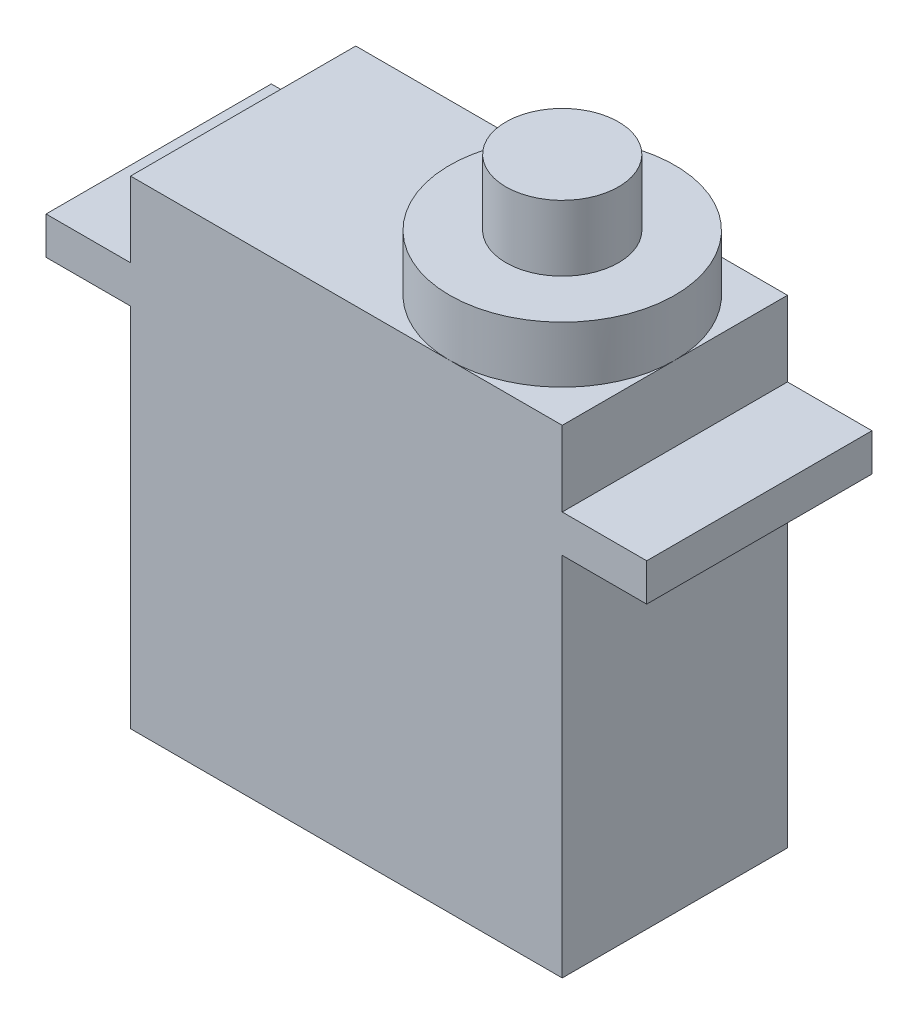
from build123d import *

# Parameters (mm, degrees)
SKETCH1_W           = 23
SKETCH1_H           = 12
BOSS_EXTRUDE1_DEPTH = 19.5
SKETCH2_W           = 4.5
SKETCH2_H           = 12
SKETCH2_W_2         = 23
BOSS_EXTRUDE2_DEPTH = 2
SKETCH3_W           = 23
SKETCH3_H           = 12
BOSS_EXTRUDE3_DEPTH = 4
BOSS_EXTRUDE4_DEPTH = 3
SKETCH5_R           = 3
BOSS_EXTRUDE5_DEPTH = 3.5


with BuildPart() as part:
    # Sketch1 → Boss-Extrude1 (new body)
    with BuildSketch(Plane(origin=(0, 0, 0), x_dir=(1, 0, 0), z_dir=(0, 1, 0))):
        with Locations((11.5, 6)):
            Rectangle(SKETCH1_W, SKETCH1_H)
    extrude(amount=BOSS_EXTRUDE1_DEPTH)

    # Sketch2 → Boss-Extrude2 (add)
    with BuildSketch(Plane(origin=(0, 19.5, 0), x_dir=(1, 0, 0), z_dir=(0, 1, 0))):
        with Locations((-2.25, 6)):
            Rectangle(SKETCH2_W, SKETCH2_H)
        with Locations((25.25, 6)):
            Rectangle(SKETCH2_W, SKETCH2_H)
        with Locations((11.5, 6)):
            Rectangle(SKETCH2_W_2, SKETCH2_H)
    extrude(amount=BOSS_EXTRUDE2_DEPTH)

    # Sketch3 → Boss-Extrude3 (add)
    with BuildSketch(Plane(origin=(0, 21.5, 0), x_dir=(1, 0, 0), z_dir=(0, 1, 0))):
        with Locations((11.5, 6)):
            Rectangle(SKETCH3_W, SKETCH3_H)
    extrude(amount=BOSS_EXTRUDE3_DEPTH)

    # Sketch4 → Boss-Extrude4 (add)
    with BuildSketch(Plane(origin=(0, 25.5, 0), x_dir=(1, 0, 0), z_dir=(0, 1, 0))):
        with BuildLine():
            ThreePointArc((12.757359313, 1.757359313), (14.703899406, 0.456722805), (17, 0))
            ThreePointArc((17, 0), (21.242640687, 1.757359313), (23, 6))
            ThreePointArc((23, 6), (22.543277195, 8.296100594), (21.242640687, 10.242640687))
            Line((21.242640687, 10.242640687), (12.757359313, 1.757359313))
        make_face()
        with BuildLine():
            ThreePointArc((11, 6), (11.456722805, 3.703899406), (12.757359313, 1.757359313))
            Line((12.757359313, 1.757359313), (21.242640687, 10.242640687))
            ThreePointArc((21.242640687, 10.242640687), (19.296100594, 11.543277195), (17, 12))
            ThreePointArc((17, 12), (12.757359313, 10.242640687), (11, 6))
        make_face()
    extrude(amount=BOSS_EXTRUDE4_DEPTH)

    # Sketch5 → Boss-Extrude5 (add)
    with BuildSketch(Plane(origin=(0, 28.5, 0), x_dir=(1, 0, 0), z_dir=(0, 1, 0))):
        with Locations((17, 6)):
            Circle(SKETCH5_R)
    extrude(amount=BOSS_EXTRUDE5_DEPTH)


solid = part.part
